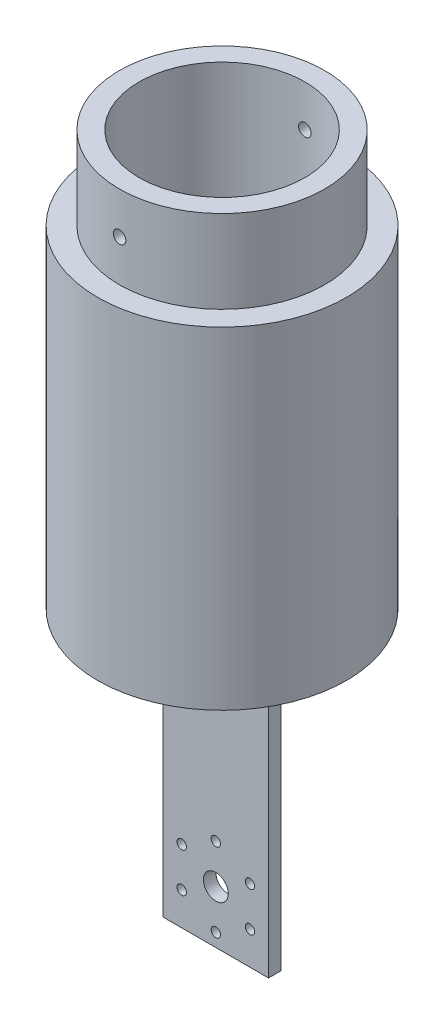
from build123d import *

# Parameters (mm, degrees)
SKETCH2_W                 = 25.4
SKETCH2_H                 = 3
BOSS_EXTRUDE1_DEPTH       = 70
SKETCH4_R                 = 30
BOSS_EXTRUDE2_DEPTH       = 10
SKETCH5_R                 = 30
SKETCH5_R_2               = 20
BOSS_EXTRUDE3_DEPTH       = 70
SKETCH8_R                 = 24.75
SKETCH8_R_2               = 20
BOSS_EXTRUDE4_DEPTH       = 20
SKETCH9_R                 = 1.5
CUT_EXTRUDE4_DEPTH        = 29.5
CUT_EXTRUDE4_DEPTH_BACK   = 32.5
F_4_40_TAPPED_HOLE1_D     = 2.2606
F_4_40_TAPPED_HOLE1_DEPTH = 7.6
F_4_40_TAPPED_HOLE1_TIP   = 0.679152758
SKETCH3_R                 = 3
CUT_EXTRUDE5_DEPTH        = 10
SKETCH12_R                = 27
SKETCH12_R_2              = 20
CUT_EXTRUDE6_DEPTH        = 60


with BuildPart() as part:
    # Sketch2 → Boss-Extrude1 (new body)
    with BuildSketch(Plane(origin=(0, 0, 0), x_dir=(1, 0, 0), z_dir=(0, 1, 0))):
        with Locations((12.7, 1.5)):
            Rectangle(SKETCH2_W, SKETCH2_H)
    extrude(amount=BOSS_EXTRUDE1_DEPTH)

    # Sketch4 → Boss-Extrude2 (add)
    with BuildSketch(Plane(origin=(0, 70, 0), x_dir=(1, 0, 0), z_dir=(0, 1, 0))):
        with Locations((12.7, 1.5)):
            Circle(SKETCH4_R)
    extrude(amount=BOSS_EXTRUDE2_DEPTH)

    # Sketch5 → Boss-Extrude3 (add)
    with BuildSketch(Plane(origin=(0, 80, 0), x_dir=(1, 0, 0), z_dir=(0, 1, 0))):
        with Locations((12.7, 1.5)):
            Circle(SKETCH5_R)
        with Locations((12.7, 1.5)):
            Circle(SKETCH5_R_2, mode=Mode.SUBTRACT)
    extrude(amount=BOSS_EXTRUDE3_DEPTH)

    # Sketch8 → Boss-Extrude4 (add)
    with BuildSketch(Plane(origin=(0, 150, 0), x_dir=(1, 0, 0), z_dir=(0, 1, 0))):
        with Locations((12.7, 1.5)):
            Circle(SKETCH8_R)
        with Locations((12.7, 1.5)):
            Circle(SKETCH8_R_2, mode=Mode.SUBTRACT)
    extrude(amount=BOSS_EXTRUDE4_DEPTH)

    # Sketch9 → Cut-Extrude4 (cut, two sides)
    with BuildSketch(Plane.XY) as cut_extrude4_sk:
        with Locations((12.7, 160)):
            Circle(SKETCH9_R)
    extrude(amount=CUT_EXTRUDE4_DEPTH, mode=Mode.SUBTRACT)
    extrude(cut_extrude4_sk.sketch, amount=-CUT_EXTRUDE4_DEPTH_BACK, mode=Mode.SUBTRACT)

    # #4-40 Tapped Hole1
    with Locations(Plane.XY):
        with Locations((12.7, 22.2), (20.927241336, 17.45), (20.927241336, 7.95), (12.7, 3.2), (4.472758664, 7.95), (4.472758664, 17.45)):
            Hole(F_4_40_TAPPED_HOLE1_D / 2, depth=F_4_40_TAPPED_HOLE1_DEPTH)
            with Locations((0, 0, -(F_4_40_TAPPED_HOLE1_DEPTH + F_4_40_TAPPED_HOLE1_TIP / 2))):  # 118° drill point
                Cone(0, F_4_40_TAPPED_HOLE1_D / 2, F_4_40_TAPPED_HOLE1_TIP, mode=Mode.SUBTRACT)

    # Sketch3 → Cut-Extrude5 (cut)
    with BuildSketch(Plane.XY):
        with Locations((12.7, 12.7)):
            Circle(SKETCH3_R)
    extrude(amount=-CUT_EXTRUDE5_DEPTH, mode=Mode.SUBTRACT)

    # Sketch12 → Cut-Extrude6 (cut)
    with BuildSketch(Plane(origin=(0, 80, 0), x_dir=(1, 0, 0), z_dir=(0, 1, 0))):
        with Locations((12.7, 1.5)):
            Circle(SKETCH12_R)
        with Locations((12.7, 1.5)):
            Circle(SKETCH12_R_2, mode=Mode.SUBTRACT)
    extrude(amount=CUT_EXTRUDE6_DEPTH, mode=Mode.SUBTRACT)


solid = part.part
